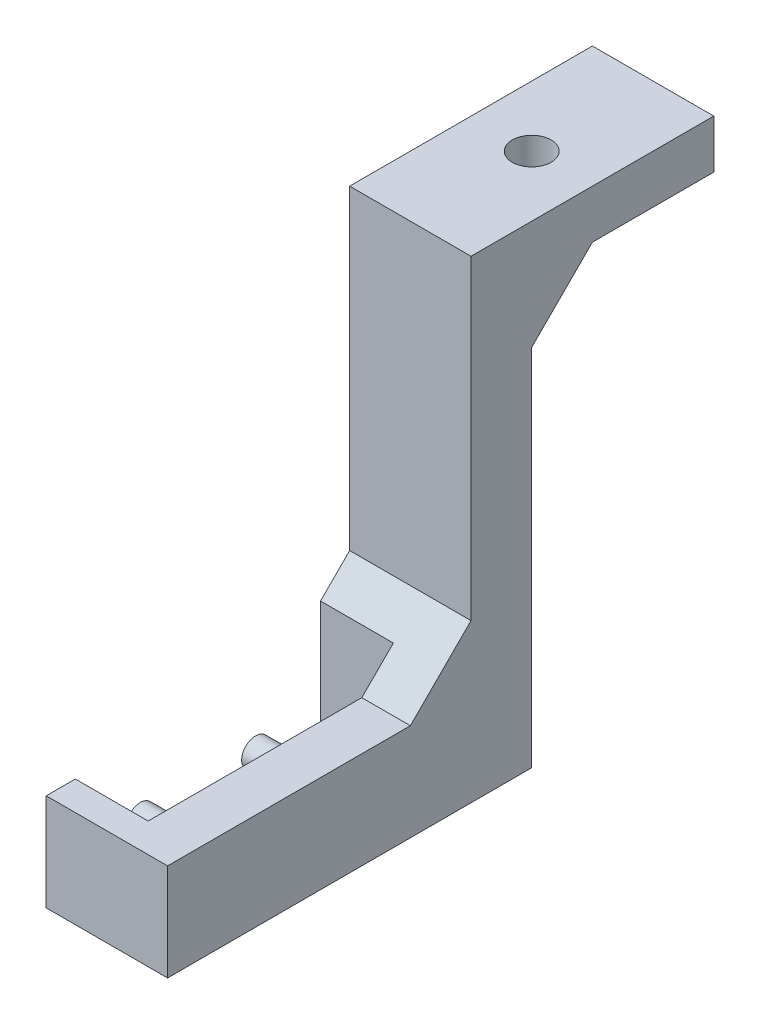
from build123d import *

# Parameters (mm, degrees)
EXTRUDE_1_DEPTH     = 5
SKETCH_2_W          = 20.2
SKETCH_2_H          = 8
CUT_EXTRUDE_1_DEPTH = 6
SKETCH_3_R          = 1.15
EXTRUDE_2_DEPTH     = 6
CHAMFER_1_SIZE      = 5
SKETCH_4_R          = 3
CUT_EXTRUDE_2_DEPTH = 6
SKETCH_5_R          = 1.6
CUT_EXTRUDE_3_DEPTH = 5


with BuildPart() as part:
    # 草图1 → 凸台-拉伸1 (new body, symmetric)
    with BuildSketch(Plane(origin=(0, 0, 0), x_dir=(0, 0, -1), z_dir=(1, 0, 0))):
        Polygon((0, 0), (30, 0), (30, 35), (45, 35), (45, 39), (25, 39), (25, 8), (0, 8), align=None)
    extrude(amount=EXTRUDE_1_DEPTH, both=True)

    # 草图2 → 切除-拉伸1 (cut)
    with BuildSketch(Plane.ZY.offset(5)):
        with Locations((-12.5, 4)):
            Rectangle(SKETCH_2_W, SKETCH_2_H)
    extrude(amount=-CUT_EXTRUDE_1_DEPTH, mode=Mode.SUBTRACT)

    # 草图3 → 凸台-拉伸2 (add)
    with BuildSketch(Plane.ZY.offset(-1)):
        with Locations((-17.25, 2.5)):
            Circle(SKETCH_3_R)
        with Locations((-7.75, 2.5)):
            Circle(SKETCH_3_R)
    extrude(amount=EXTRUDE_2_DEPTH)

    # 倒角1
    chamfer_1_edges = [part.edges().sort_by_distance(p)[0] for p in [
        (0, 8, -25),
        (0, 35, -30),
    ]]
    chamfer(chamfer_1_edges, length=CHAMFER_1_SIZE)

    # 草图4 → 切除-拉伸2 (cut)
    with BuildSketch(Plane.XZ.offset(-35)):
        with Locations((0, -35)):
            Circle(SKETCH_4_R)
    extrude(amount=CUT_EXTRUDE_2_DEPTH, mode=Mode.SUBTRACT)

    # 草图5 → 切除-拉伸3 (cut, through all)
    with BuildSketch(Plane.XZ.offset(-35)):
        with Locations((0, -35)):
            Circle(SKETCH_5_R)
    extrude(amount=-CUT_EXTRUDE_3_DEPTH, mode=Mode.SUBTRACT)


solid = part.part
